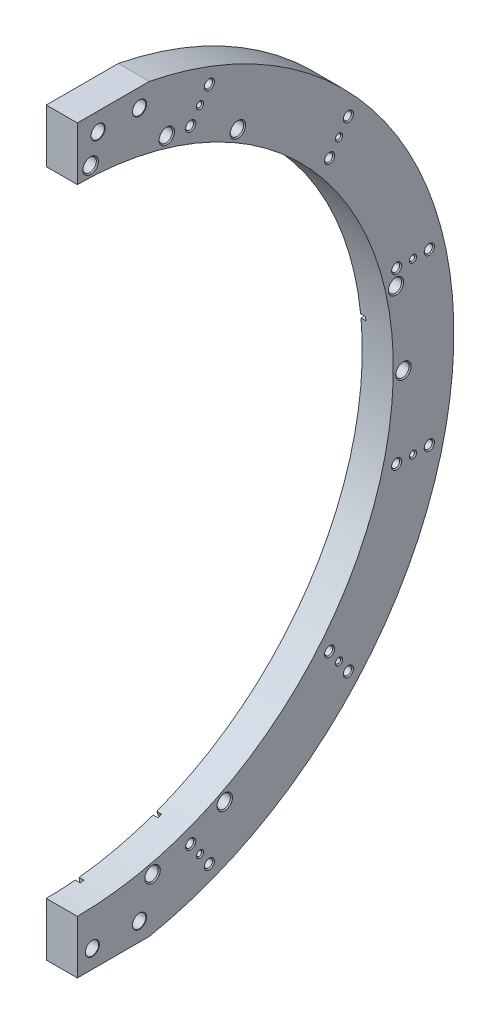
from build123d import *

# Parameters (mm, degrees)
SKETCH1_W                             = 19.05
SKETCH1_H                             = 38.1
REVOLVE_THIN1_ANGLE                   = 180
SKETCH81_W                            = 0.5
SKETCH81_H                            = 500
EXTRUDE1_DEPTH                        = 20.05
CLEARANCE_HOLE1_AT_2_COUNT            = 2
CLEARANCE_HOLE1_AT_2_PITCH            = 20
CLEARANCE_HOLE1_AT_3_COUNT            = 2
CLEARANCE_HOLE1_AT_3_PITCH            = 104
CLEARANCE_HOLE1_AT_4_COUNT            = 2
CLEARANCE_HOLE1_AT_4_PITCH            = 105.905618359
F_1_8_0_125_DIAMETER_HOLE1_AT_2_COUNT = 2
F_1_8_0_125_DIAMETER_HOLE1_AT_2_PITCH = 104
F_1_8_0_125_DIAMETER_HOLE1_AT_3_COUNT = 2
F_1_8_0_125_DIAMETER_HOLE1_AT_3_PITCH = 195.60569338
F_1_8_0_125_DIAMETER_HOLE1_AT_4_COUNT = 2
F_1_8_0_125_DIAMETER_HOLE1_AT_4_PITCH = 10
CIRPATTERN1_COUNT                     = 3
CIRPATTERN1_ANGLE                     = 110
SKETCH88_W                            = 44.153457313
SKETCH88_H                            = 4.349459722
CUT_EXTRUDE1_DEPTH                    = 20.05
F_5_16_CLEARANCE_HOLE1_AT_2_COUNT     = 2
F_5_16_CLEARANCE_HOLE1_AT_2_PITCH     = 25.4
F_5_16_CLEARANCE_HOLE1_AT_3_COUNT     = 2
F_5_16_CLEARANCE_HOLE1_AT_3_PITCH     = 431.8
F_5_16_CLEARANCE_HOLE1_AT_4_COUNT     = 2
F_5_16_CLEARANCE_HOLE1_AT_4_PITCH     = 432.767106737
CUT_EXTRUDE2_REACH                    = 21.05
F_5_16_CLEARANCE_HOLE2_AT_2_COUNT     = 2
F_5_16_CLEARANCE_HOLE2_AT_2_PITCH     = 47.3
F_5_16_CLEARANCE_HOLE2_AT_3_COUNT     = 2
F_5_16_CLEARANCE_HOLE2_AT_3_PITCH     = 93.939454723
F_5_16_CLEARANCE_HOLE2_AT_4_COUNT     = 2
F_5_16_CLEARANCE_HOLE2_AT_4_PITCH     = 244.781722588
F_5_16_CLEARANCE_HOLE2_AT_5_COUNT     = 2
F_5_16_CLEARANCE_HOLE2_AT_5_PITCH     = 280.53523627
F_5_16_CLEARANCE_HOLE2_AT_6_COUNT     = 2
F_5_16_CLEARANCE_HOLE2_AT_6_PITCH     = 387.803850818
F_5_16_CLEARANCE_HOLE2_AT_7_COUNT     = 2
F_5_16_CLEARANCE_HOLE2_AT_7_PITCH     = 397.097312716
CUT_EXTRUDE_THIN5_DEPTH               = 3
CUT_EXTRUDE_THIN7_DEPTH               = 3
CUT_EXTRUDE_THIN8_DEPTH               = 3
CUT_EXTRUDE_THIN9_DEPTH               = 3
CUT_EXTRUDE_THIN10_DEPTH              = 3
FILLET1_R                             = 1.190625


with BuildPart() as part:
    # Sketch1 → Revolve-Thin1 (revolve)
    with BuildSketch(Plane.XY):
        with Locations((9.525, 212.3125)):
            Rectangle(SKETCH1_W, SKETCH1_H)
    revolve(axis=Axis((0, 0, 0), (-1, 0, 0)), revolution_arc=REVOLVE_THIN1_ANGLE)

    # Sketch81 → Extrude1 (cut, through all)
    with BuildSketch(Plane(origin=(0, 0, 0), x_dir=(0, 0, -1), z_dir=(1, 0, 0))):
        with Locations((0.25, 0)):
            Rectangle(SKETCH81_W, SKETCH81_H)
    extrude(amount=EXTRUDE1_DEPTH, mode=Mode.SUBTRACT)

    # Sketch82 → Clearance Hole1 (revolve, cut)
    with BuildSketch(Plane(origin=(0, 147.356612489, -166.660489486), x_dir=(0, 0, 1), z_dir=(0, 1, 0))):
        Polygon((0, 0), (0, 19.05), (3.1242, 19.05), (2.4892, 18.415), (2.4892, 0), align=None)
    clearance_hole1 = revolve(axis=Axis((-6.35, 147.356612489, -166.660489486), (1, 0, 0)), mode=Mode.SUBTRACT)

    # Clearance Hole1 at 2: Clearance Hole1 ×2
    with Locations(*[Vector(0, -0.819152044, 0.573576436) * (i * CLEARANCE_HOLE1_AT_2_PITCH) for i in range(1, CLEARANCE_HOLE1_AT_2_COUNT)]):
        add(clearance_hole1, mode=Mode.SUBTRACT)

    # Clearance Hole1 at 3: Clearance Hole1 ×2
    with Locations(*[Vector(0, 0.573576436, 0.819152044) * (i * CLEARANCE_HOLE1_AT_3_PITCH) for i in range(1, CLEARANCE_HOLE1_AT_3_COUNT)]):
        add(clearance_hole1, mode=Mode.SUBTRACT)

    # Clearance Hole1 at 4: Clearance Hole1 ×2
    with Locations(*[Vector(0, 0.40856103, 0.912731004) * (i * CLEARANCE_HOLE1_AT_4_PITCH) for i in range(1, CLEARANCE_HOLE1_AT_4_COUNT)]):
        add(clearance_hole1, mode=Mode.SUBTRACT)

    # Sketch86 → 1_8 _0.125_ Diameter Hole1 (revolve, cut)
    with BuildSketch(Plane(origin=(19.05, 198.817041427, -75.732912516), x_dir=(0, 0, -1), z_dir=(0, 1, 0))):
        Polygon((0, 0), (0, 19.05), (2.2225, 19.05), (1.5875, 18.415), (1.5875, 0.635), (2.2225, 0), align=None)
    f_1_8_0_125_diameter_hole1 = revolve(axis=Axis((25.4, 198.817041427, -75.732912516), (-1, 0, 0)), mode=Mode.SUBTRACT)

    # 1_8 _0.125_ Diameter Hole1 at 2: 1_8 _0.125_ Diameter Hole1 ×2
    with Locations(*[Vector(0, -0.573576436, -0.819152044) * (i * F_1_8_0_125_DIAMETER_HOLE1_AT_2_PITCH) for i in range(1, F_1_8_0_125_DIAMETER_HOLE1_AT_2_COUNT)]):
        add(f_1_8_0_125_diameter_hole1, mode=Mode.SUBTRACT)

    # 1_8 _0.125_ Diameter Hole1 at 3: 1_8 _0.125_ Diameter Hole1 ×2
    with Locations(*[Vector(0, -0.954817271, -0.297193505) * (i * F_1_8_0_125_DIAMETER_HOLE1_AT_3_PITCH) for i in range(1, F_1_8_0_125_DIAMETER_HOLE1_AT_3_COUNT)]):
        add(f_1_8_0_125_diameter_hole1, mode=Mode.SUBTRACT)

    # 1_8 _0.125_ Diameter Hole1 at 4: 1_8 _0.125_ Diameter Hole1 ×2
    with Locations(*[Vector(0, 0.819152044, -0.573576436) * (i * F_1_8_0_125_DIAMETER_HOLE1_AT_4_PITCH) for i in range(1, F_1_8_0_125_DIAMETER_HOLE1_AT_4_COUNT)]):
        add(f_1_8_0_125_diameter_hole1, mode=Mode.SUBTRACT)

    # CirPattern1: 1_8 _0.125_ Diameter Hole1, Clearance Hole1 ×3 about axis
    cirpattern1_axis = Axis((0, 0, 0), (-1, 0, 0))
    add([f_1_8_0_125_diameter_hole1.rotate(cirpattern1_axis, i * CIRPATTERN1_ANGLE / (CIRPATTERN1_COUNT - 1)) for i in range(1, CIRPATTERN1_COUNT)], mode=Mode.SUBTRACT)
    add([clearance_hole1.rotate(cirpattern1_axis, i * CIRPATTERN1_ANGLE / (CIRPATTERN1_COUNT - 1)) for i in range(1, CIRPATTERN1_COUNT)], mode=Mode.SUBTRACT)

    # CirPattern1 copy 1 sketch → CirPattern1 copy 1 (revolve, cut)
    with BuildSketch(Plane(origin=(19.05, -52, -206.3), x_dir=(0, -0.819152044, -0.573576436), z_dir=(0, 0.573576436, -0.819152044))):
        Polygon((0, 0), (0, 19.05), (2.2225, 19.05), (1.5875, 18.415), (1.5875, 0.635), (2.2225, 0), align=None)
    revolve(axis=Axis((25.4, -52, -206.3), (-1, 0, 0)), mode=Mode.SUBTRACT)

    # CirPattern1 copy 2 sketch → CirPattern1 copy 2 (revolve, cut)
    with BuildSketch(Plane(origin=(19.05, -198.817041427, -75.732912516), x_dir=(0, -0.939692621, 0.342020143), z_dir=(0, -0.342020143, -0.939692621))):
        Polygon((0, 0), (0, 19.05), (2.2225, 19.05), (1.5875, 18.415), (1.5875, 0.635), (2.2225, 0), align=None)
    revolve(axis=Axis((25.4, -198.817041427, -75.732912516), (-1, 0, 0)), mode=Mode.SUBTRACT)

    # CirPattern1 copy 3 sketch → CirPattern1 copy 3 (revolve, cut)
    with BuildSketch(Plane(origin=(19.05, -102.745102668, -86.652432191), x_dir=(0, -0.819152044, -0.573576436), z_dir=(0, 0.573576436, -0.819152044))):
        Polygon((0, 0), (0, 19.05), (2.2225, 19.05), (1.5875, 18.415), (1.5875, 0.635), (2.2225, 0), align=None)
    revolve(axis=Axis((25.4, -102.745102668, -86.652432191), (-1, 0, 0)), mode=Mode.SUBTRACT)

    # CirPattern1 copy 4 sketch → CirPattern1 copy 4 (revolve, cut)
    with BuildSketch(Plane(origin=(19.05, -129.913686813, 34.462067634), x_dir=(0, -0.939692621, 0.342020143), z_dir=(0, -0.342020143, -0.939692621))):
        Polygon((0, 0), (0, 19.05), (2.2225, 19.05), (1.5875, 18.415), (1.5875, 0.635), (2.2225, 0), align=None)
    revolve(axis=Axis((25.4, -129.913686813, 34.462067634), (-1, 0, 0)), mode=Mode.SUBTRACT)

    # CirPattern1 copy 5 sketch → CirPattern1 copy 5 (revolve, cut)
    with BuildSketch(Plane(origin=(19.05, 52, -216.3), x_dir=(0, -0.819152044, -0.573576436), z_dir=(0, 0.573576436, -0.819152044))):
        Polygon((0, 0), (0, 19.05), (2.2225, 19.05), (1.5875, 18.415), (1.5875, 0.635), (2.2225, 0), align=None)
    revolve(axis=Axis((25.4, 52, -216.3), (-1, 0, 0)), mode=Mode.SUBTRACT)

    # CirPattern1 copy 6 sketch → CirPattern1 copy 6 (revolve, cut)
    with BuildSketch(Plane(origin=(19.05, -147.356612489, -166.660489486), x_dir=(0, -0.939692621, 0.342020143), z_dir=(0, -0.342020143, -0.939692621))):
        Polygon((0, 0), (0, 19.05), (2.2225, 19.05), (1.5875, 18.415), (1.5875, 0.635), (2.2225, 0), align=None)
    revolve(axis=Axis((25.4, -147.356612489, -166.660489486), (-1, 0, 0)), mode=Mode.SUBTRACT)

    # CirPattern1 copy 7 sketch → CirPattern1 copy 7 (revolve, cut)
    with BuildSketch(Plane(origin=(0, -52, -196.3), x_dir=(0, 0.819152044, 0.573576436), z_dir=(0, 0.573576436, -0.819152044))):
        Polygon((0, 0), (0, 19.05), (3.1242, 19.05), (2.4892, 18.415), (2.4892, 0), align=None)
    revolve(axis=Axis((-6.35, -52, -196.3), (1, 0, 0)), mode=Mode.SUBTRACT)

    # CirPattern1 copy 8 sketch → CirPattern1 copy 8 (revolve, cut)
    with BuildSketch(Plane(origin=(0, -190.625520984, -69.997148153), x_dir=(0, 0.939692621, -0.342020143), z_dir=(0, -0.342020143, -0.939692621))):
        Polygon((0, 0), (0, 19.05), (3.1242, 19.05), (2.4892, 18.415), (2.4892, 0), align=None)
    revolve(axis=Axis((-6.35, -190.625520984, -69.997148153), (1, 0, 0)), mode=Mode.SUBTRACT)

    # CirPattern1 copy 9 sketch → CirPattern1 copy 9 (revolve, cut)
    with BuildSketch(Plane(origin=(0, 52, -216.3), x_dir=(0, 0.819152044, 0.573576436), z_dir=(0, 0.573576436, -0.819152044))):
        Polygon((0, 0), (0, 19.05), (3.1242, 19.05), (2.4892, 18.415), (2.4892, 0), align=None)
    revolve(axis=Axis((-6.35, 52, -216.3), (1, 0, 0)), mode=Mode.SUBTRACT)

    # CirPattern1 copy 10 sketch → CirPattern1 copy 10 (revolve, cut)
    with BuildSketch(Plane(origin=(0, -147.356612489, -166.660489486), x_dir=(0, 0.939692621, -0.342020143), z_dir=(0, -0.342020143, -0.939692621))):
        Polygon((0, 0), (0, 19.05), (3.1242, 19.05), (2.4892, 18.415), (2.4892, 0), align=None)
    revolve(axis=Axis((-6.35, -147.356612489, -166.660489486), (1, 0, 0)), mode=Mode.SUBTRACT)

    # CirPattern1 copy 11 sketch → CirPattern1 copy 11 (revolve, cut)
    with BuildSketch(Plane(origin=(0, 52, -196.3), x_dir=(0, 0.819152044, 0.573576436), z_dir=(0, 0.573576436, -0.819152044))):
        Polygon((0, 0), (0, 19.05), (3.1242, 19.05), (2.4892, 18.415), (2.4892, 0), align=None)
    revolve(axis=Axis((-6.35, 52, -196.3), (1, 0, 0)), mode=Mode.SUBTRACT)

    # CirPattern1 copy 12 sketch → CirPattern1 copy 12 (revolve, cut)
    with BuildSketch(Plane(origin=(0, -130.973571604, -155.188960759), x_dir=(0, 0.939692621, -0.342020143), z_dir=(0, -0.342020143, -0.939692621))):
        Polygon((0, 0), (0, 19.05), (3.1242, 19.05), (2.4892, 18.415), (2.4892, 0), align=None)
    revolve(axis=Axis((-6.35, -130.973571604, -155.188960759), (1, 0, 0)), mode=Mode.SUBTRACT)

    # Sketch88 → Cut-Extrude1 (cut, through all)
    with BuildSketch(Plane.ZY):
        with Locations((-22.576728657, 229.187229861)):
            Rectangle(SKETCH88_W, SKETCH88_H)
        with Locations((-22.576728657, -229.187229861)):
            Rectangle(SKETCH88_W, SKETCH88_H)
    extrude(amount=-CUT_EXTRUDE1_DEPTH, mode=Mode.SUBTRACT)

    # Sketch89 → 5_16 Clearance Hole1 (revolve, cut)
    with BuildSketch(Plane(origin=(0, 215.9, -38.6), x_dir=(0, 0, 1), z_dir=(0, 1, 0))):
        Polygon((0, 0), (0, 19.05), (4.318, 19.05), (4.1021, 18.8341), (4.1021, 0.2159), (4.318, 0), align=None)
    f_5_16_clearance_hole1 = revolve(axis=Axis((-6.35, 215.9, -38.6), (1, 0, 0)), mode=Mode.SUBTRACT)

    # 5_16 Clearance Hole1 at 2: 5_16 Clearance Hole1 ×2
    with Locations(*[(0, 0, i * F_5_16_CLEARANCE_HOLE1_AT_2_PITCH) for i in range(1, F_5_16_CLEARANCE_HOLE1_AT_2_COUNT)]):
        add(f_5_16_clearance_hole1, mode=Mode.SUBTRACT)

    # 5_16 Clearance Hole1 at 3: 5_16 Clearance Hole1 ×2
    with Locations(*[(0, -i * F_5_16_CLEARANCE_HOLE1_AT_3_PITCH, 0) for i in range(1, F_5_16_CLEARANCE_HOLE1_AT_3_COUNT)]):
        add(f_5_16_clearance_hole1, mode=Mode.SUBTRACT)

    # 5_16 Clearance Hole1 at 4: 5_16 Clearance Hole1 ×2
    with Locations(*[Vector(0, -0.997765295, 0.066816283) * (i * F_5_16_CLEARANCE_HOLE1_AT_4_PITCH) for i in range(1, F_5_16_CLEARANCE_HOLE1_AT_4_COUNT)]):
        add(f_5_16_clearance_hole1, mode=Mode.SUBTRACT)

    # Sketch91 → Cut-Extrude2 (cut, up to next)
    with BuildSketch(Plane(origin=(19.05, 0, 0), x_dir=(0, 0, -1), z_dir=(1, 0, 0)), mode=Mode.PRIVATE) as cut_extrude2_sk1:
        with BuildLine():
            Line((0, -194.2625), (0, -193.2625))
            ThreePointArc((0, -193.2625), (193.2625, 0), (0, 193.2625))
            Line((0, 193.2625), (0, 194.2625))
            ThreePointArc((0, 194.2625), (194.2625, 0), (0, -194.2625))
        make_face()
    cut_extrude2_tool1 = extrude(cut_extrude2_sk1.sketch, amount=-CUT_EXTRUDE2_REACH, mode=Mode.PRIVATE) & part.part
    add(cut_extrude2_tool1.solids().sort_by_distance((19.05, 0, -193.828116))[0], mode=Mode.SUBTRACT)

    # Sketch94 → 5_16 Clearance Hole2 (revolve, cut)
    with BuildSketch(Plane(origin=(0, 200.292404118, -8.65810169), x_dir=(0, 0, 1), z_dir=(0, 1, 0))):
        Polygon((0, 0), (0, 19.05), (4.7371, 19.05), (4.1021, 18.415), (4.1021, 0.635), (4.7371, 0), align=None)
    f_5_16_clearance_hole2 = revolve(axis=Axis((-6.35, 200.292404118, -8.65810169), (1, 0, 0)), mode=Mode.SUBTRACT)

    # 5_16 Clearance Hole2 at 2: 5_16 Clearance Hole2 ×2
    with Locations(*[Vector(0, -0.160742566, -0.986996367) * (i * F_5_16_CLEARANCE_HOLE2_AT_2_PITCH) for i in range(1, F_5_16_CLEARANCE_HOLE2_AT_2_COUNT)]):
        add(f_5_16_clearance_hole2, mode=Mode.SUBTRACT)

    # 5_16 Clearance Hole2 at 3: 5_16 Clearance Hole2 ×2
    with Locations(*[Vector(0, -0.27605338, -0.961142305) * (i * F_5_16_CLEARANCE_HOLE2_AT_3_PITCH) for i in range(1, F_5_16_CLEARANCE_HOLE2_AT_3_COUNT)]):
        add(f_5_16_clearance_hole2, mode=Mode.SUBTRACT)

    # 5_16 Clearance Hole2 at 4: 5_16 Clearance Hole2 ×2
    with Locations(*[Vector(0, -0.644126319, -0.764919136) * (i * F_5_16_CLEARANCE_HOLE2_AT_4_PITCH) for i in range(1, F_5_16_CLEARANCE_HOLE2_AT_4_COUNT)]):
        add(f_5_16_clearance_hole2, mode=Mode.SUBTRACT)

    # 5_16 Clearance Hole2 at 5: 5_16 Clearance Hole2 ×2
    with Locations(*[Vector(0, -0.729864073, -0.683592302) * (i * F_5_16_CLEARANCE_HOLE2_AT_5_PITCH) for i in range(1, F_5_16_CLEARANCE_HOLE2_AT_5_COUNT)]):
        add(f_5_16_clearance_hole2, mode=Mode.SUBTRACT)

    # 5_16 Clearance Hole2 at 6: 5_16 Clearance Hole2 ×2
    with Locations(*[Vector(0, -0.977260308, -0.212043136) * (i * F_5_16_CLEARANCE_HOLE2_AT_6_PITCH) for i in range(1, F_5_16_CLEARANCE_HOLE2_AT_6_COUNT)]):
        add(f_5_16_clearance_hole2, mode=Mode.SUBTRACT)

    # 5_16 Clearance Hole2 at 7: 5_16 Clearance Hole2 ×2
    with Locations(*[Vector(0, -0.995424444, -0.095551959) * (i * F_5_16_CLEARANCE_HOLE2_AT_7_PITCH) for i in range(1, F_5_16_CLEARANCE_HOLE2_AT_7_COUNT)]):
        add(f_5_16_clearance_hole2, mode=Mode.SUBTRACT)

    # Sketch95 → Cut-Extrude-Thin5 (cut)
    with BuildSketch(Plane.ZY):
        Polygon((-29.851714725, 190.761755321), (-30.816170119, 196.68373352), (-33.184961399, 196.297951363), (-32.220506005, 190.375973164), align=None)
    extrude(amount=-CUT_EXTRUDE_THIN5_DEPTH, mode=Mode.SUBTRACT)

    # Sketch97 → Cut-Extrude-Thin7 (cut)
    with BuildSketch(Plane.ZY):
        Polygon((-78.251396852, 183.059679512), (-75.926342223, 177.528484255), (-73.71386412, 178.458506106), (-76.038918749, 183.989701363), align=None)
    extrude(amount=-CUT_EXTRUDE_THIN7_DEPTH, mode=Mode.SUBTRACT)

    # Sketch98 → Cut-Extrude-Thin8 (cut)
    with BuildSketch(Plane.ZY):
        Polygon((-198.278092506, 17.886458692), (-192.305715316, 17.311384177), (-192.07568551, 19.700335053), (-198.0480627, 20.275409568), align=None)
    extrude(amount=-CUT_EXTRUDE_THIN8_DEPTH, mode=Mode.SUBTRACT)

    # Sketch99 → Cut-Extrude-Thin9 (cut)
    with BuildSketch(Plane.ZY):
        Polygon((-67.619198408, -187.254802686), (-65.547369623, -181.623859116), (-67.79974705, -180.795127602), (-69.871575836, -186.426071171), align=None)
    extrude(amount=-CUT_EXTRUDE_THIN9_DEPTH, mode=Mode.SUBTRACT)

    # Sketch100 → Cut-Extrude-Thin10 (cut)
    with BuildSketch(Plane.ZY):
        Polygon((-18.702491825, -197.796059293), (-18.101616257, -191.826222733), (-20.489550881, -191.585872506), (-21.090426449, -197.555709066), align=None)
    extrude(amount=-CUT_EXTRUDE_THIN10_DEPTH, mode=Mode.SUBTRACT)

    # Fillet1
    fillet1_edges = [part.edges().sort_by_distance(p)[0] for p in [
        (1.5, 196.68373352, -30.816170119),
        (1.5, 196.297951363, -33.184961399),
        (1.5, 183.989701363, -76.038918749),
        (1.5, 183.059679512, -78.251396852),
        (1.5, 20.275409568, -198.0480627),
        (1.5, 17.886458692, -198.278092506),
        (1.5, -186.426071171, -69.871575836),
        (1.5, -187.254802686, -67.619198408),
        (1.5, -197.555709066, -21.090426449),
        (1.5, -197.796059293, -18.702491825),
    ]]
    fillet(fillet1_edges, radius=FILLET1_R)


solid = part.part
